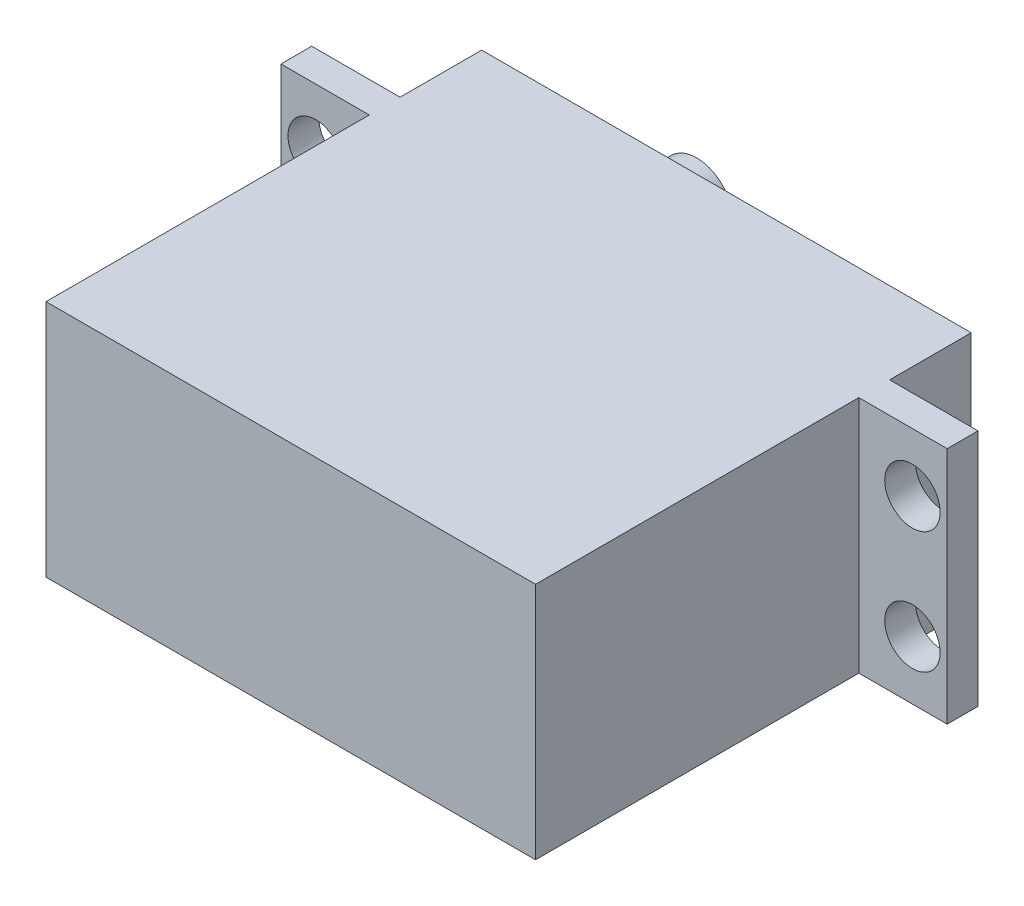
from build123d import *

# Parameters (mm, degrees)
BOSS_EXTRUDE1_DEPTH = 19.685
SKETCH3_R           = 2.9845
BOSS_EXTRUDE2_DEPTH = 8.0264
CUT_EXTRUDE1_REACH  = 31.21
SKETCH4_R           = 2.286


with BuildPart() as part:
    # Sketch1 → Boss-Extrude1 (new body)
    with BuildSketch(Plane(origin=(0, 0, 0), x_dir=(1, 0, 0), z_dir=(0, 1, 0))):
        Polygon((0, 29.21), (0, 35.941), (40.386, 35.941), (40.386, 29.21), (47.6758, 29.21), (47.6758, 26.67), (40.386, 26.67), (40.386, 0), (0, 0), (0, 26.67), (-7.2898, 26.67), (-7.2898, 29.21), align=None)
    extrude(amount=BOSS_EXTRUDE1_DEPTH)

    # Sketch3 → Boss-Extrude2 (add)
    with BuildSketch(Plane(origin=(0, 0, -35.941), x_dir=(-1, 0, 0), z_dir=(0, 0, -1))):
        with Locations((-9.7155, 9.8425)):
            Circle(SKETCH3_R)
    extrude(amount=BOSS_EXTRUDE2_DEPTH)

    # Sketch4 → Cut-Extrude1 (cut, up to next)
    with BuildSketch(Plane(origin=(0, 0, -29.21), x_dir=(-1, 0, 0), z_dir=(0, 0, -1)), mode=Mode.PRIVATE) as cut_extrude1_sk1:
        with Locations((-44.8056, 14.859)):
            Circle(SKETCH4_R)
    cut_extrude1_tool1 = extrude(cut_extrude1_sk1.sketch, amount=-CUT_EXTRUDE1_REACH, mode=Mode.PRIVATE) & part.part
    add(cut_extrude1_tool1.solids().sort_by_distance((44.8056, 14.859, -29.21))[0], mode=Mode.SUBTRACT)
    # Sketch4 → Cut-Extrude1 (cut, up to next)
    with BuildSketch(Plane(origin=(0, 0, -29.21), x_dir=(-1, 0, 0), z_dir=(0, 0, -1)), mode=Mode.PRIVATE) as cut_extrude1_sk2:
        with Locations((-44.8056, 4.826)):
            Circle(SKETCH4_R)
    cut_extrude1_tool2 = extrude(cut_extrude1_sk2.sketch, amount=-CUT_EXTRUDE1_REACH, mode=Mode.PRIVATE) & part.part
    add(cut_extrude1_tool2.solids().sort_by_distance((44.8056, 4.826, -29.21))[0], mode=Mode.SUBTRACT)
    # Sketch4 → Cut-Extrude1 (cut, up to next)
    with BuildSketch(Plane(origin=(0, 0, -29.21), x_dir=(-1, 0, 0), z_dir=(0, 0, -1)), mode=Mode.PRIVATE) as cut_extrude1_sk3:
        with Locations((4.4196, 14.859)):
            Circle(SKETCH4_R)
    cut_extrude1_tool3 = extrude(cut_extrude1_sk3.sketch, amount=-CUT_EXTRUDE1_REACH, mode=Mode.PRIVATE) & part.part
    add(cut_extrude1_tool3.solids().sort_by_distance((-4.4196, 14.859, -29.21))[0], mode=Mode.SUBTRACT)
    # Sketch4 → Cut-Extrude1 (cut, up to next)
    with BuildSketch(Plane(origin=(0, 0, -29.21), x_dir=(-1, 0, 0), z_dir=(0, 0, -1)), mode=Mode.PRIVATE) as cut_extrude1_sk4:
        with Locations((4.4196, 4.826)):
            Circle(SKETCH4_R)
    cut_extrude1_tool4 = extrude(cut_extrude1_sk4.sketch, amount=-CUT_EXTRUDE1_REACH, mode=Mode.PRIVATE) & part.part
    add(cut_extrude1_tool4.solids().sort_by_distance((-4.4196, 4.826, -29.21))[0], mode=Mode.SUBTRACT)


solid = part.part
